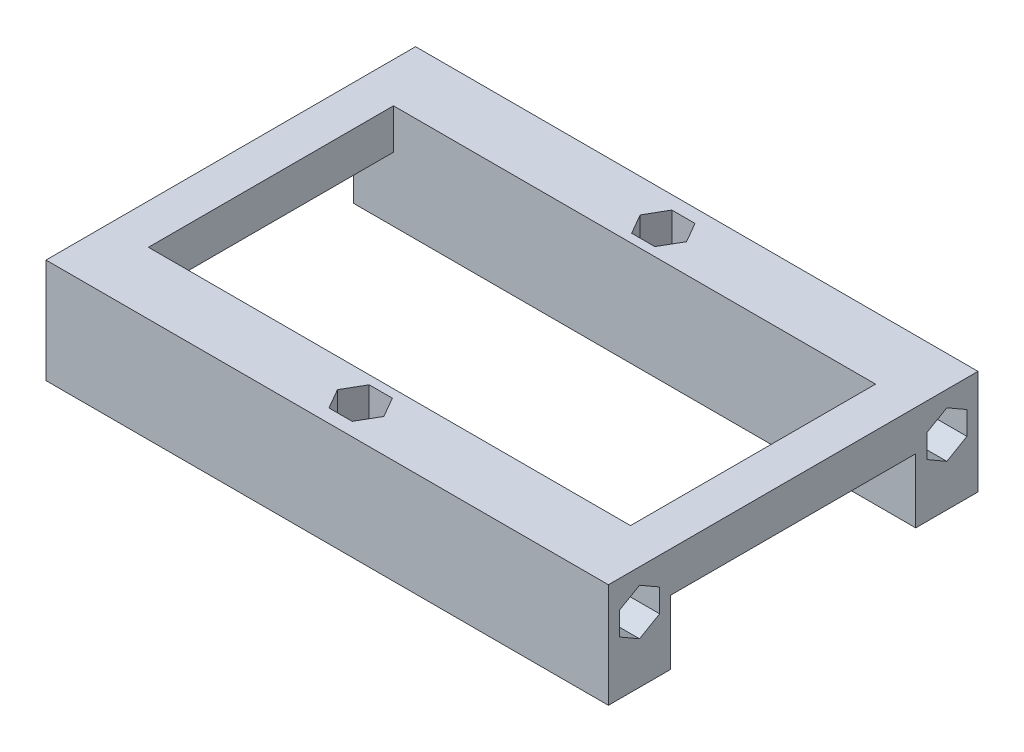
from build123d import *

# Parameters (mm, degrees)
SKETCH1_W           = 70
SKETCH1_H           = 46
BOSS_EXTRUDE1_DEPTH = 5
SKETCH2_W           = 60
SKETCH2_H           = 30.5
CUT_EXTRUDE1_DEPTH  = 5
SKETCH3_W           = 70
SKETCH3_H           = 7.75
BOSS_EXTRUDE2_DEPTH = 8
CUT_EXTRUDE4_DEPTH  = 8.5
CUT_EXTRUDE5_DEPTH  = 8.5
CUT_EXTRUDE6_DEPTH  = 8.5


with BuildPart() as part:
    # Sketch1 → Boss-Extrude1 (new body)
    with BuildSketch(Plane(origin=(0, 0, 0), x_dir=(1, 0, 0), z_dir=(0, 1, 0))):
        Rectangle(SKETCH1_W, SKETCH1_H)
    extrude(amount=BOSS_EXTRUDE1_DEPTH)

    # Sketch2 → Cut-Extrude1 (cut)
    with BuildSketch(Plane(origin=(0, 0, 0), x_dir=(1, 0, 0), z_dir=(0, 1, 0))):
        Rectangle(SKETCH2_W, SKETCH2_H)
    extrude(amount=CUT_EXTRUDE1_DEPTH, mode=Mode.SUBTRACT)

    # Sketch3 → Boss-Extrude2 (add)
    with BuildSketch(Plane(origin=(0, 0, 0), x_dir=(1, 0, 0), z_dir=(0, 1, 0))):
        with Locations((0, -19.125)):
            Rectangle(SKETCH3_W, SKETCH3_H)
        with Locations((0, 19.125)):
            Rectangle(SKETCH3_W, SKETCH3_H)
    extrude(amount=-BOSS_EXTRUDE2_DEPTH)

    # Sketch6 → Cut-Extrude4 (cut)
    with BuildSketch(Plane.ZY.offset(35)):
        Polygon((19.125, -2.761751346), (21.625, -1.318375673), (21.625, 1.568375673), (19.125, 3.011751346), (16.625, 1.568375673), (16.625, -1.318375673), align=None)
        Polygon((-19.125, -2.761751346), (-16.625, -1.318375673), (-16.625, 1.568375673), (-19.125, 3.011751346), (-21.625, 1.568375673), (-21.625, -1.318375673), align=None)
    extrude(amount=-CUT_EXTRUDE4_DEPTH, mode=Mode.SUBTRACT)

    # Sketch7 → Cut-Extrude5 (cut)
    with BuildSketch(Plane(origin=(35, 0, 0), x_dir=(0, 0, -1), z_dir=(1, 0, 0))):
        Polygon((-19.125, -2.761751346), (-16.625, -1.318375673), (-16.625, 1.568375673), (-19.125, 3.011751346), (-21.625, 1.568375673), (-21.625, -1.318375673), align=None)
        Polygon((19.125, -2.761751346), (21.625, -1.318375673), (21.625, 1.568375673), (19.125, 3.011751346), (16.625, 1.568375673), (16.625, -1.318375673), align=None)
    extrude(amount=-CUT_EXTRUDE5_DEPTH, mode=Mode.SUBTRACT)

    # Sketch10 → Cut-Extrude6 (cut)
    with BuildSketch(Plane(origin=(0, 5, 0), x_dir=(1, 0, 0), z_dir=(0, 1, 0))):
        Polygon((2.886751346, 18.835), (1.443375673, 21.335), (-1.443375673, 21.335), (-2.886751346, 18.835), (-1.443375673, 16.335), (1.443375673, 16.335), align=None)
        Polygon((2.886751346, -18.835), (1.443375673, -16.335), (-1.443375673, -16.335), (-2.886751346, -18.835), (-1.443375673, -21.335), (1.443375673, -21.335), align=None)
    extrude(amount=-CUT_EXTRUDE6_DEPTH, mode=Mode.SUBTRACT)


solid = part.part
